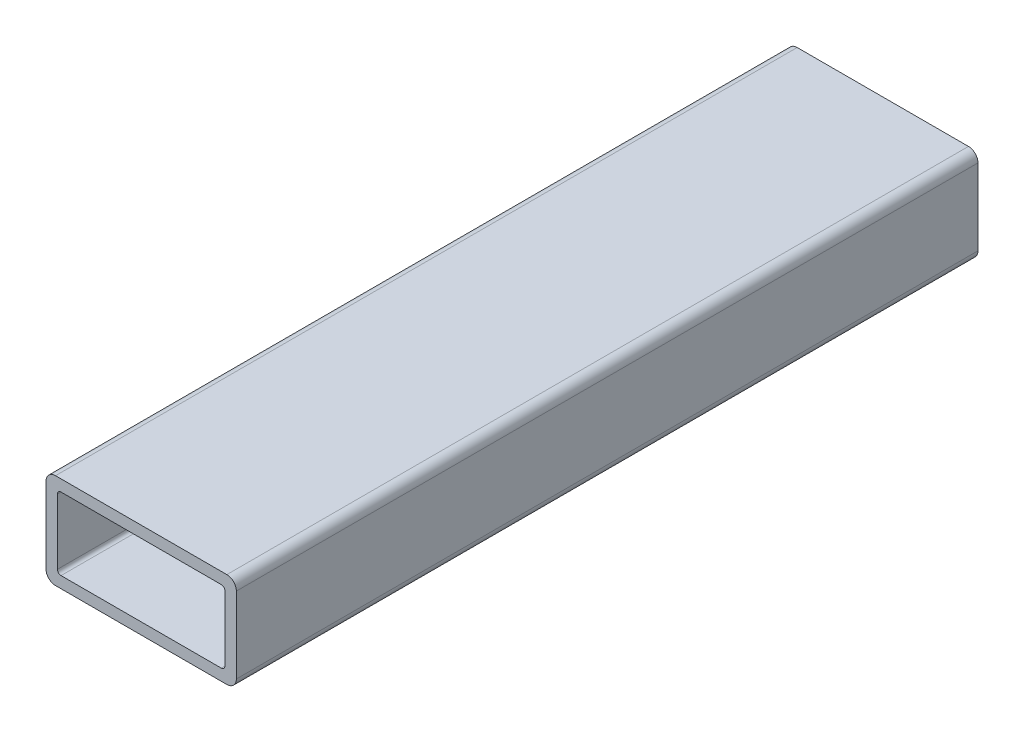
from build123d import *

# Parameters (mm, degrees)
BOSS_EXTRUDE1_DEPTH = 197.91934


with BuildPart() as part:
    # Sketch4 → Boss-Extrude1 (new body)
    with BuildSketch(Plane.XY):
        with BuildLine():
            Line((25.4, -10.16), (25.4, 10.16))
            ThreePointArc((25.4, 10.16), (24.656051224, 11.956051224), (22.86, 12.7))
            Line((22.86, 12.7), (-22.86, 12.7))
            ThreePointArc((-22.86, 12.7), (-24.656051224, 11.956051224), (-25.4, 10.16))
            Line((-25.4, 10.16), (-25.4, -10.16))
            ThreePointArc((-25.4, -10.16), (-24.656051224, -11.956051224), (-22.86, -12.7))
            Line((-22.86, -12.7), (22.86, -12.7))
            ThreePointArc((22.86, -12.7), (24.656051224, -11.956051224), (25.4, -10.16))
        make_face()
        with BuildLine():
            Line((22.352, 8.6868), (22.352, -8.6868))
            ThreePointArc((22.352, -8.6868), (22.069299465, -9.369299465), (21.3868, -9.652))
            Line((21.3868, -9.652), (-21.3868, -9.652))
            ThreePointArc((-21.3868, -9.652), (-22.069299465, -9.369299465), (-22.352, -8.6868))
            Line((-22.352, -8.6868), (-22.352, 8.6868))
            ThreePointArc((-22.352, 8.6868), (-22.069299465, 9.369299465), (-21.3868, 9.652))
            Line((-21.3868, 9.652), (21.3868, 9.652))
            ThreePointArc((21.3868, 9.652), (22.069299465, 9.369299465), (22.352, 8.6868))
        make_face(mode=Mode.SUBTRACT)
    extrude(amount=BOSS_EXTRUDE1_DEPTH)


solid = part.part
